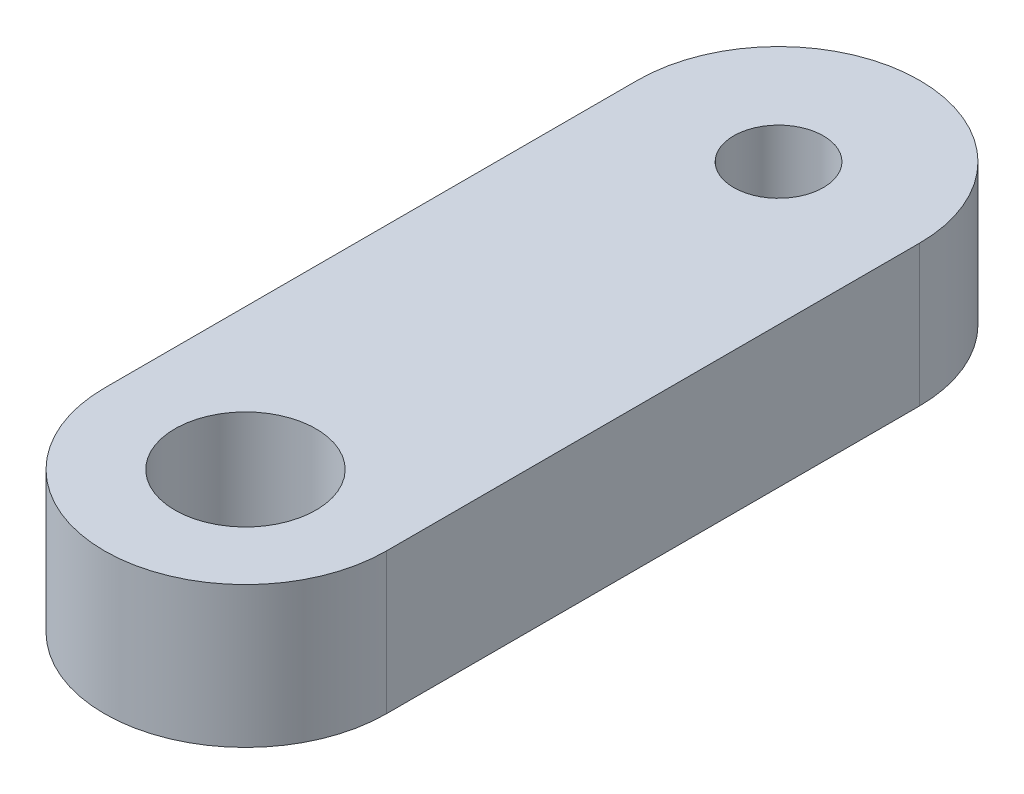
from build123d import *

# Parameters (mm, degrees)
SKETCH1_R              = 3.175
BOSS_EXTRUDE1_DEPTH    = 6.35
F_10_32_TAPPED_HOLE1_D = 4.0386


with BuildPart() as part:
    # Sketch1 → Boss-Extrude1 (new body)
    with BuildSketch(Plane(origin=(0, 0, 0), x_dir=(1, 0, 0), z_dir=(0, 1, 0))):
        with BuildLine():
            Line((6.35, 24), (6.35, 0))
            ThreePointArc((6.35, 0), (0, -6.35), (-6.35, 0))
            Line((-6.35, 0), (-6.35, 24))
            ThreePointArc((-6.35, 24), (0, 30.35), (6.35, 24))
        make_face()
        Circle(SKETCH1_R, mode=Mode.SUBTRACT)
    extrude(amount=BOSS_EXTRUDE1_DEPTH)

    # #10-32 Tapped Hole1 (through all)
    with Locations(Plane(origin=(0, 6.35, 0), x_dir=(1, 0, 0), z_dir=(0, 1, 0))):
        with Locations((0, 24)):
            Hole(F_10_32_TAPPED_HOLE1_D / 2)


solid = part.part
